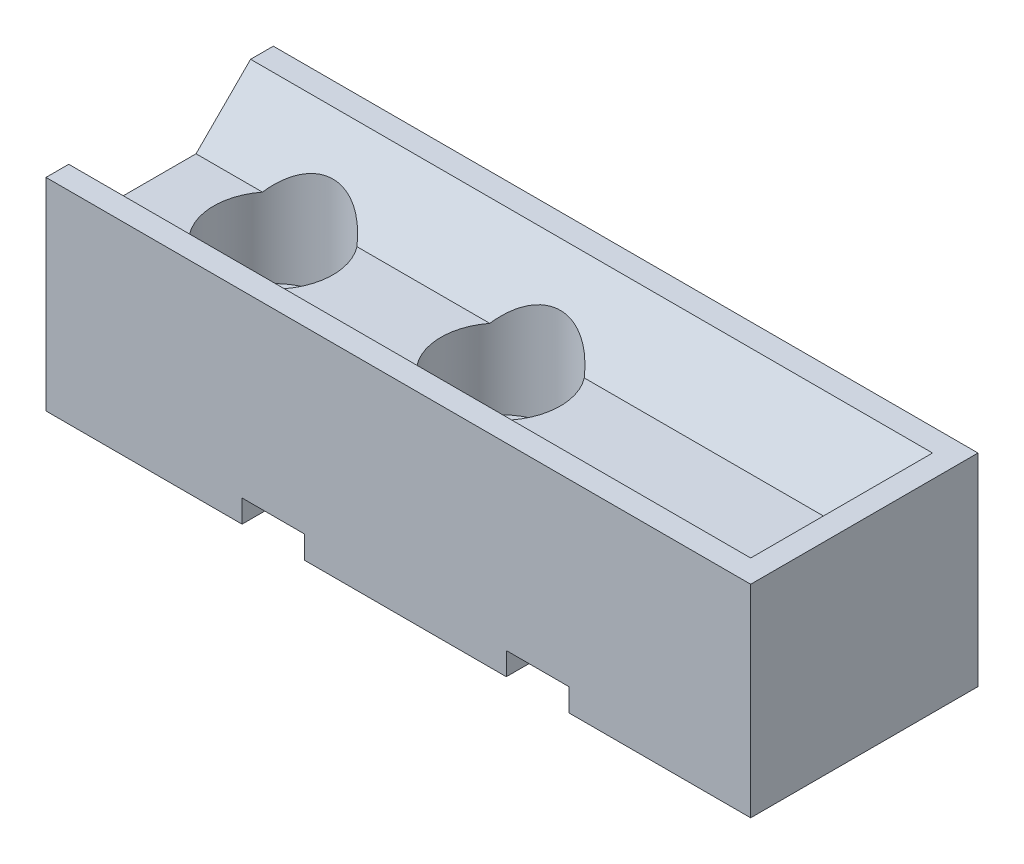
from build123d import *

# Parameters (mm, degrees)
SKETCH1_W           = 62
SKETCH1_H           = 20
BOSS_EXTRUDE1_DEPTH = 13
BOSS_EXTRUDE2_DEPTH = 62
SKETCH3_W           = 2
SKETCH3_H           = 20
BOSS_EXTRUDE3_DEPTH = 4.8
SKETCH6_R           = 2.75
CUT_EXTRUDE1_DEPTH  = 14
CUT_EXTRUDE2_START  = 6
SKETCH7_R           = 5.25
CUT_EXTRUDE2_DEPTH  = 12.8
SKETCH8_W           = 5.5
SKETCH8_H           = 2
CUT_EXTRUDE3_DEPTH  = 21


with BuildPart() as part:
    # Sketch1 → Boss-Extrude1 (new body)
    with BuildSketch(Plane(origin=(0, 0, 0), x_dir=(1, 0, 0), z_dir=(0, 1, 0))):
        Rectangle(SKETCH1_W, SKETCH1_H)
    extrude(amount=BOSS_EXTRUDE1_DEPTH)

    # Sketch2 → Boss-Extrude2 (add)
    with BuildSketch(Plane.ZY.offset(31)):
        Polygon((3.2, 13), (8, 17.8), (10, 17.8), (10, 13), align=None)
        Polygon((-10, 13), (-3.2, 13), (-8, 17.8), (-10, 17.8), align=None)
    extrude(amount=-BOSS_EXTRUDE2_DEPTH)

    # Sketch3 → Boss-Extrude3 (add)
    with BuildSketch(Plane(origin=(0, 13, 0), x_dir=(1, 0, 0), z_dir=(0, 1, 0))):
        with Locations((30, 0)):
            Rectangle(SKETCH3_W, SKETCH3_H)
    extrude(amount=BOSS_EXTRUDE3_DEPTH)

    # Sketch6 → Cut-Extrude1 (cut, through all)
    with BuildSketch(Plane(origin=(0, 13, 0), x_dir=(1, 0, 0), z_dir=(0, 1, 0))):
        with Locations((-21, 0)):
            Circle(SKETCH6_R)
        with Locations((-1, 0)):
            Circle(SKETCH6_R)
    extrude(amount=-CUT_EXTRUDE1_DEPTH, mode=Mode.SUBTRACT)

    # Sketch7 → Cut-Extrude2 (cut, through all)
    with BuildSketch(Plane(origin=(0, 0, 0), x_dir=(1, 0, 0), z_dir=(0, 1, 0)).offset(CUT_EXTRUDE2_START)):
        with Locations((-21, 0)):
            Circle(SKETCH7_R)
        with Locations((-1, 0)):
            Circle(SKETCH7_R)
    extrude(amount=CUT_EXTRUDE2_DEPTH, mode=Mode.SUBTRACT)

    # Sketch8 → Cut-Extrude3 (cut, through all)
    with BuildSketch(Plane(origin=(0, 0, -10), x_dir=(-1, 0, 0), z_dir=(0, 0, -1))):
        with Locations((-12.25, 1)):
            Rectangle(SKETCH8_W, SKETCH8_H)
        with Locations((11, 1)):
            Rectangle(SKETCH8_W, SKETCH8_H)
    extrude(amount=-CUT_EXTRUDE3_DEPTH, mode=Mode.SUBTRACT)


solid = part.part
